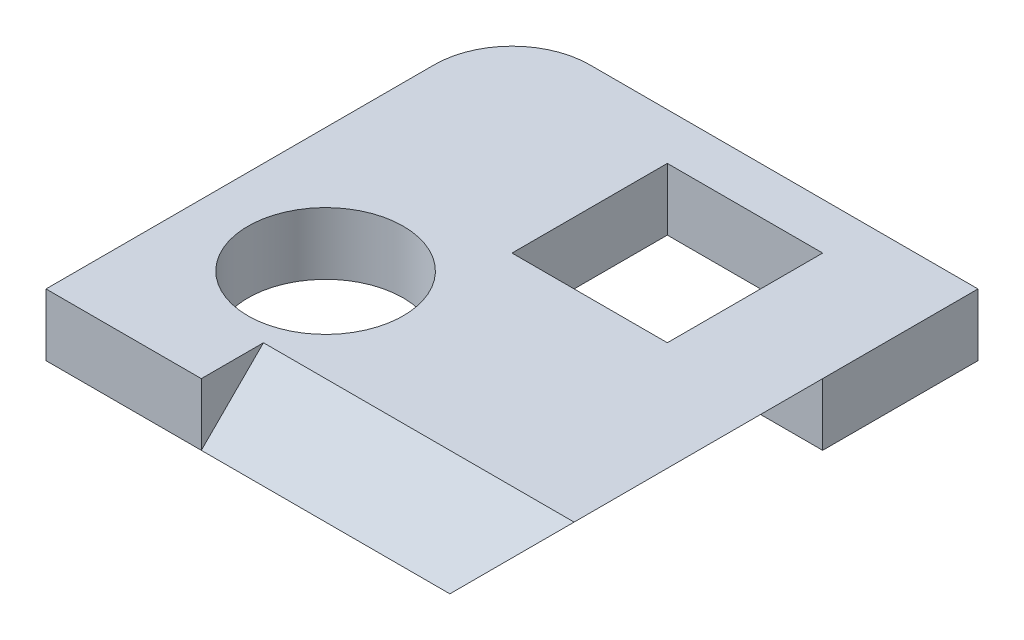
from build123d import *

# Parameters (mm, degrees)
SKETCH1_W           = 30
SKETCH1_H           = 30
BOSS_EXTRUDE1_DEPTH = 4
SKETCH2_R           = 5
SKETCH2_W           = 10
SKETCH2_H           = 10
CUT_EXTRUDE1_DEPTH  = 5
FILLET1_R           = 5
CUT_EXTRUDE2_DEPTH  = 20
CUT_EXTRUDE3_DEPTH  = 20


with BuildPart() as part:
    # Sketch1 → Boss-Extrude1 (new body)
    with BuildSketch(Plane(origin=(0, 0, 0), x_dir=(1, 0, 0), z_dir=(0, 1, 0))):
        with Locations((15, 15)):
            Rectangle(SKETCH1_W, SKETCH1_H)
    extrude(amount=BOSS_EXTRUDE1_DEPTH)

    # Sketch2 → Cut-Extrude1 (cut, through all)
    with BuildSketch(Plane(origin=(0, 4, 0), x_dir=(1, 0, 0), z_dir=(0, 1, 0))):
        with Locations(Location((8, 10, 0), (0, 0, 270))):  # turned: the seam where the file's is
            Circle(SKETCH2_R)
        with Locations((18, 22)):
            Rectangle(SKETCH2_W, SKETCH2_H)
    extrude(amount=-CUT_EXTRUDE1_DEPTH, mode=Mode.SUBTRACT)

    # Fillet1
    fillet1_edges = [part.edges().sort_by_distance(p)[0] for p in [
        (0, 2, -30),
    ]]
    fillet(fillet1_edges, radius=FILLET1_R)

    # Sketch3 → Cut-Extrude2 (cut)
    with BuildSketch(Plane(origin=(30, 0, 0), x_dir=(0, 0, -1), z_dir=(1, 0, 0))):
        Polygon((0, 0), (4, 4), (0, 4), align=None)
    extrude(amount=-CUT_EXTRUDE2_DEPTH, mode=Mode.SUBTRACT)

    # Sketch4 → Cut-Extrude3 (cut)
    with BuildSketch(Plane.XY):
        Polygon((30, 4), (26, 0), (30, 0), align=None)
    extrude(amount=-CUT_EXTRUDE3_DEPTH, mode=Mode.SUBTRACT)


solid = part.part
